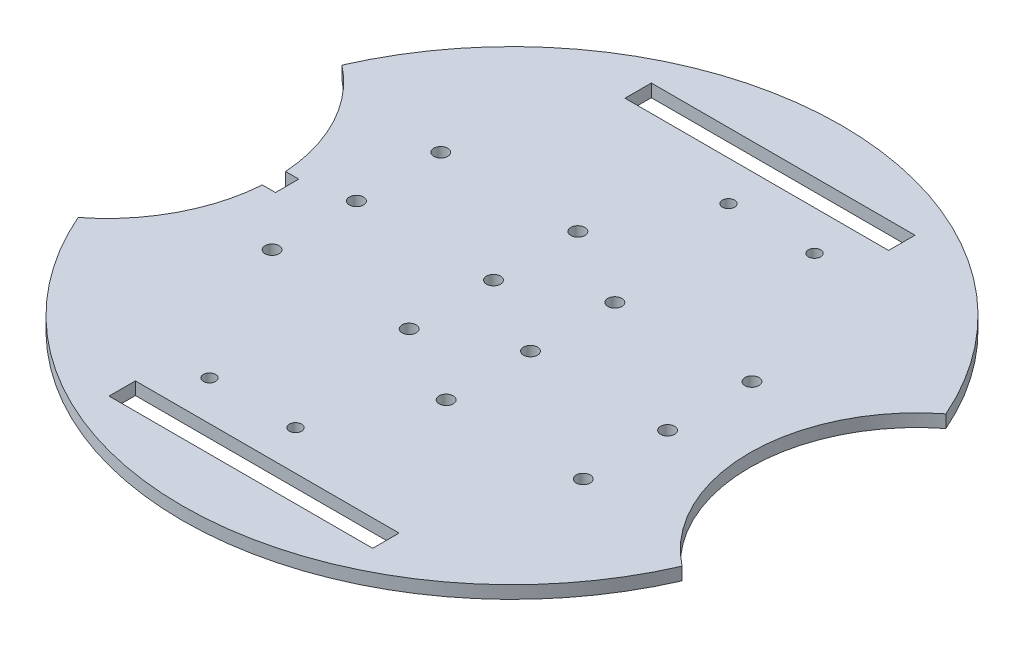
from build123d import *

# Parameters (mm, degrees)
SKETCH1_R           = 75
BOSS_EXTRUDE1_DEPTH = 2.9
SKETCH2_R           = 1.6
SKETCH2_R_2         = 1.4
SKETCH2_W           = 60
SKETCH2_H           = 6
CUT_EXTRUDE1_DEPTH  = 10
CUT_EXTRUDE2_DEPTH  = 3.9


with BuildPart() as part:
    # Sketch1 → Boss-Extrude1 (new body)
    with BuildSketch(Plane(origin=(0, 0, 0), x_dir=(1, 0, 0), z_dir=(0, 1, 0))):
        Circle(SKETCH1_R)
    extrude(amount=BOSS_EXTRUDE1_DEPTH)

    # Sketch2 → Cut-Extrude1 (cut)
    with BuildSketch(Plane(origin=(0, 2.9, 0), x_dir=(1, 0, 0), z_dir=(0, 1, 0))):
        with BuildLine():
            ThreePointArc((-68.72850121, -30.023209712), (-54.08520342, 0), (-68.72850121, 30.023209712))
            ThreePointArc((-68.72850121, 30.023209712), (-75, 0), (-68.72850121, -30.023209712))
        make_face()
        with BuildLine():
            ThreePointArc((75, 0), (73.415385277, 15.335618821), (68.72850121, 30.023209712))
            ThreePointArc((68.72850121, 30.023209712), (54.08520342, 0), (68.72850121, -30.023209712))
            ThreePointArc((68.72850121, -30.023209712), (73.415385277, -15.335618821), (75, 0))
        make_face()
        with Locations((9.1, -24.090757895)):
            Circle(SKETCH2_R)
        with Locations((40.3, -24.090757895)):
            Circle(SKETCH2_R)
        with Locations((40.3, -4.890757895)):
            Circle(SKETCH2_R)
        with Locations((40.3, 14.309242105)):
            Circle(SKETCH2_R)
        with Locations((9.1, 14.309242105)):
            Circle(SKETCH2_R)
        with Locations((9.1, -4.890757895)):
            Circle(SKETCH2_R)
        with Locations((-9.1, 4.890757895)):
            Circle(SKETCH2_R)
        with Locations((-9.1, -14.309242105)):
            Circle(SKETCH2_R)
        with Locations((-9.1, 24.090757895)):
            Circle(SKETCH2_R)
        with Locations((-40.3, 24.090757895)):
            Circle(SKETCH2_R)
        with Locations((-40.3, 4.890757895)):
            Circle(SKETCH2_R)
        with Locations((-40.3, -14.309242105)):
            Circle(SKETCH2_R)
        with Locations((-22.14, -46.709242105)):
            Circle(SKETCH2_R_2)
        with Locations((-2.56, -46.709242105)):
            Circle(SKETCH2_R_2)
        with Locations((22.14, 46.709242105)):
            Circle(SKETCH2_R_2)
        with Locations((2.56, 46.709242105)):
            Circle(SKETCH2_R_2)
        with Locations((0, -58.709242105)):
            Rectangle(SKETCH2_W, SKETCH2_H)
        with Locations((0, 58.709242105)):
            Rectangle(SKETCH2_W, SKETCH2_H)
    extrude(amount=-CUT_EXTRUDE1_DEPTH, mode=Mode.SUBTRACT)

    # Sketch3 → Cut-Extrude2 (cut, through all)
    with BuildSketch(Plane(origin=(0, 2.9, 0), x_dir=(1, 0, 0), z_dir=(0, 1, 0))):
        with BuildLine():
            Line((-51.177473943, 2.65), (-54.177473943, 2.65))
            ThreePointArc((-54.177473943, 2.65), (-54.08520342, 0), (-54.177473943, -2.65))
            Line((-54.177473943, -2.65), (-51.177473943, -2.65))
            Line((-51.177473943, -2.65), (-51.177473943, 2.65))
        make_face()
    extrude(amount=-CUT_EXTRUDE2_DEPTH, mode=Mode.SUBTRACT)


solid = part.part
